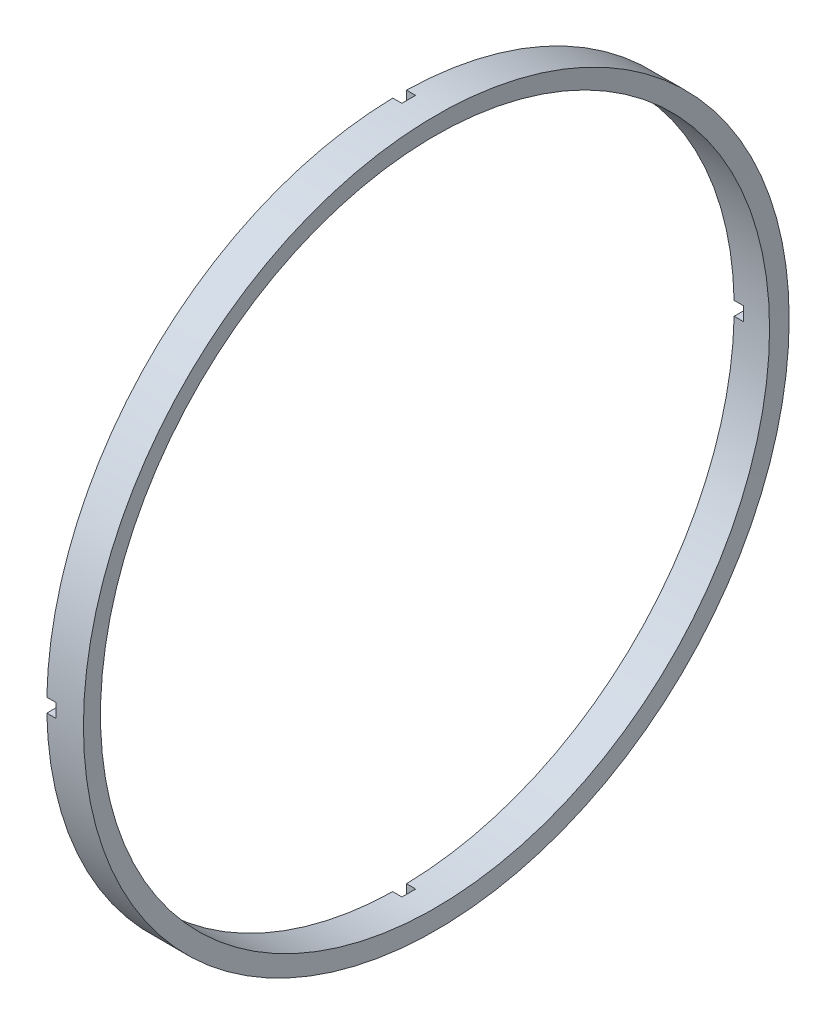
from build123d import *

# Parameters (mm, degrees)
SKICA2_W                 = 1.5
SKICA2_H                 = 77
SKICA2_W_2               = 77
SKICA2_H_2               = 1.5
ODEBRAT_VYSUNUT_M1_DEPTH = 1


with BuildPart() as part:
    # Skica1 → Rotovat1 (revolve)
    with BuildSketch(Plane.XY):
        Polygon((-23.64396546, 38.5), (-23.64396546, 36.5), (-19.783819083, 36.5), (-19.64396546, 38.5), align=None)
    revolve(axis=Axis((0, 0, 0), (-1, 0, 0)))

    # Skica2 → Odebrat vysunutím1 (cut)
    with BuildSketch(Plane.ZY.offset(23.64396546)):
        Rectangle(SKICA2_W, SKICA2_H)
        Rectangle(SKICA2_W_2, SKICA2_H_2)
    extrude(amount=-ODEBRAT_VYSUNUT_M1_DEPTH, mode=Mode.SUBTRACT)


solid = part.part
